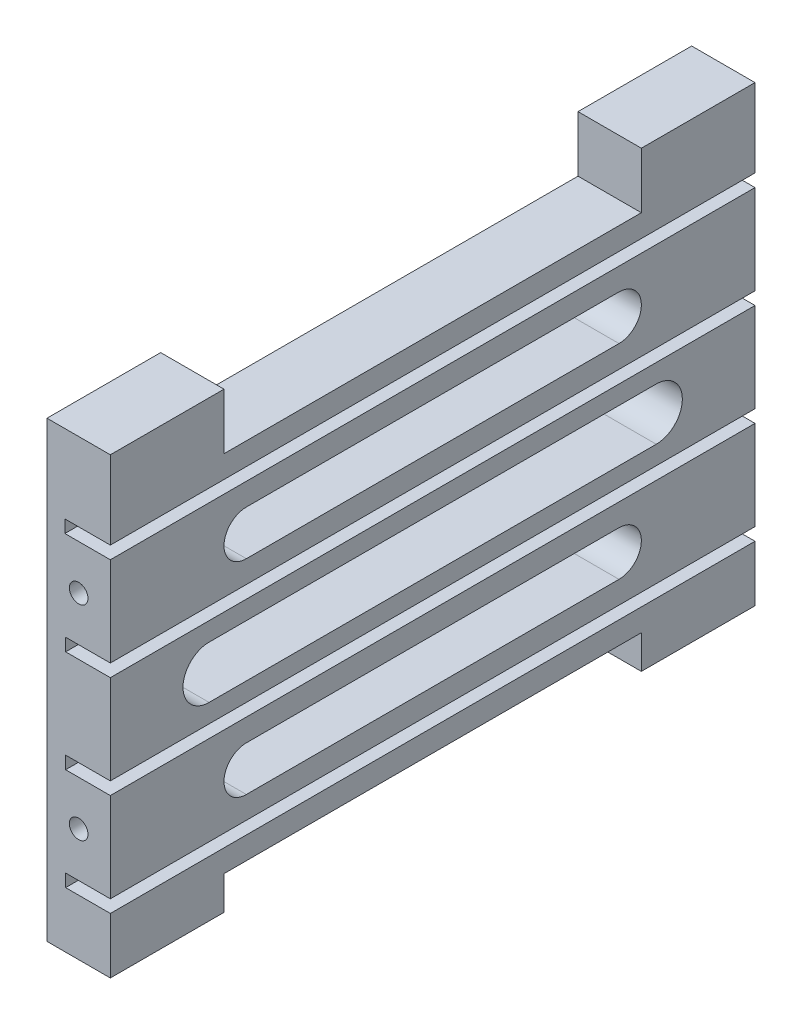
from build123d import *

# Parameters (mm, degrees)
BOSS_EXTRUDE1_DEPTH            = 86.5
M3X0_5_TAPPED_HOLE2_AT_2_COUNT = 2
M3X0_5_TAPPED_HOLE2_AT_2_PITCH = 27.4
M3X0_5_TAPPED_HOLE1_AT_2_COUNT = 2
M3X0_5_TAPPED_HOLE1_AT_2_PITCH = 49
SKETCH14_R                     = 3.5
CUT_EXTRUDE3_DEPTH             = 9.5
CUT_EXTRUDE1_DEPTH             = 9.5
SKETCH15_W                     = 56
SKETCH15_H                     = 7.5
CUT_EXTRUDE4_DEPTH             = 9.5
SKETCH16_W                     = 56
SKETCH16_H                     = 4.5
CUT_EXTRUDE5_DEPTH             = 9.5


with BuildPart() as part:
    # Sketch1 → Boss-Extrude1 (new body)
    with BuildSketch(Plane.XY):
        Polygon((0, 0), (0, 60.8), (8.5, 60.8), (8.5, 50.3), (2.4, 50.3), (2.4, 48.6), (8.5, 48.6), (8.5, 36.6), (2.5, 36.6), (2.5, 34.9), (8.5, 34.9), (8.5, 22.9), (2.5, 22.9), (2.5, 21.2), (8.5, 21.2), (8.5, 9.2), (2.5, 9.2), (2.5, 7.5), (8.5, 7.5), (8.5, 0), align=None)
    extrude(amount=BOSS_EXTRUDE1_DEPTH)

    # Sketch4 → M3x0.5 Tapped Hole2 (revolve, cut)
    with BuildSketch(Plane(origin=(4.25, 42.6, 86.5), x_dir=(0, -1, 0), z_dir=(1, 0, 0))):
        Polygon((0, 0), (0, 6.751075774), (1.25, 6), (1.25, 0), align=None)
    m3x0_5_tapped_hole2 = revolve(axis=Axis((4.25, 42.6, 92.85), (0, 0, -1)), mode=Mode.SUBTRACT)

    # M3x0.5 Tapped Hole2 at 2: M3x0.5 Tapped Hole2 ×2
    with Locations(*[(0, -i * M3X0_5_TAPPED_HOLE2_AT_2_PITCH, 0) for i in range(1, M3X0_5_TAPPED_HOLE2_AT_2_COUNT)]):
        add(m3x0_5_tapped_hole2, mode=Mode.SUBTRACT)

    # Mirror1: M3x0.5 Tapped Hole2 across plane
    add(m3x0_5_tapped_hole2.mirror(Plane.XY.offset(43.25)), mode=Mode.SUBTRACT)

    # Mirror1 copy 1 sketch → Mirror1 copy 1 (revolve, cut)
    with BuildSketch(Plane(origin=(4.25, 15.2, 0), x_dir=(0, -1, 0), z_dir=(1, 0, 0))):
        Polygon((0, 0), (0, -6.751075774), (1.25, -6), (1.25, 0), align=None)
    revolve(axis=Axis((4.25, 15.2, -6.35), (0, 0, -1)), mode=Mode.SUBTRACT)

    # Sketch11 → M3x0.5 Tapped Hole1 (revolve, cut)
    with BuildSketch(Plane(origin=(0, 5, 8.25), x_dir=(0, 0, 1), z_dir=(0, 1, 0))):
        Polygon((0, 0), (0, 4.751075774), (1.25, 4), (1.25, 0), align=None)
    m3x0_5_tapped_hole1 = revolve(axis=Axis((-6.35, 5, 8.25), (1, 0, 0)), mode=Mode.SUBTRACT)

    # M3x0.5 Tapped Hole1 at 2: M3x0.5 Tapped Hole1 ×2
    with Locations(*[(0, i * M3X0_5_TAPPED_HOLE1_AT_2_PITCH, 0) for i in range(1, M3X0_5_TAPPED_HOLE1_AT_2_COUNT)]):
        add(m3x0_5_tapped_hole1, mode=Mode.SUBTRACT)

    # Mirror2: M3x0.5 Tapped Hole1 across plane
    add(m3x0_5_tapped_hole1.mirror(Plane(origin=(0, 0, 43.25), x_dir=(1, 0, 0), z_dir=(0, 0, -1))), mode=Mode.SUBTRACT)

    # Mirror2 copy 1 sketch → Mirror2 copy 1 (revolve, cut)
    with BuildSketch(Plane(origin=(0, 54, 78.25), x_dir=(0, 0, -1), z_dir=(0, 1, 0))):
        Polygon((0, 0), (0, -4.751075774), (1.25, -4), (1.25, 0), align=None)
    revolve(axis=Axis((-6.35, 54, 78.25), (-1, 0, 0)), mode=Mode.SUBTRACT)

    # Sketch14 → Cut-Extrude3 (cut, through all)
    with BuildSketch(Plane(origin=(8.5, 0, 0), x_dir=(0, 0, -1), z_dir=(1, 0, 0))):
        with BuildLine():
            Line((-13.25, 32.4), (-73.25, 32.4))
            ThreePointArc((-73.25, 32.4), (-70.775126266, 31.374873734), (-69.75, 28.9))
            ThreePointArc((-69.75, 28.9), (-70.775126266, 26.425126266), (-73.25, 25.4))
            Line((-73.25, 25.4), (-13.25, 25.4))
            ThreePointArc((-13.25, 25.4), (-16.75, 28.9), (-13.25, 32.4))
        make_face()
        with Locations((-73.25, 28.9)):
            Circle(SKETCH14_R)
        with Locations((-13.25, 28.9)):
            Circle(SKETCH14_R)
    extrude(amount=-CUT_EXTRUDE3_DEPTH, mode=Mode.SUBTRACT)

    # Sketch12 → Cut-Extrude1 (cut, through all)
    with BuildSketch(Plane(origin=(8.5, 0, 0), x_dir=(0, 0, -1), z_dir=(1, 0, 0))):
        with BuildLine():
            Line((-18.25, 45.6), (-68.25, 45.6))
            ThreePointArc((-68.25, 45.6), (-71.25, 42.6), (-68.25, 39.6))
            Line((-68.25, 39.6), (-18.25, 39.6))
            ThreePointArc((-18.25, 39.6), (-15.25, 42.6), (-18.25, 45.6))
        make_face()
        with BuildLine():
            Line((-18.25, 18.2), (-68.25, 18.2))
            ThreePointArc((-68.25, 18.2), (-71.25, 15.2), (-68.25, 12.2))
            Line((-68.25, 12.2), (-18.25, 12.2))
            ThreePointArc((-18.25, 12.2), (-15.25, 15.2), (-18.25, 18.2))
        make_face()
    extrude(amount=-CUT_EXTRUDE1_DEPTH, mode=Mode.SUBTRACT)

    # Sketch15 → Cut-Extrude4 (cut, through all)
    with BuildSketch(Plane(origin=(8.5, 0, 0), x_dir=(0, 0, -1), z_dir=(1, 0, 0))):
        with Locations((-43.25, 57.05)):
            Rectangle(SKETCH15_W, SKETCH15_H)
    extrude(amount=-CUT_EXTRUDE4_DEPTH, mode=Mode.SUBTRACT)

    # Sketch16 → Cut-Extrude5 (cut, through all)
    with BuildSketch(Plane(origin=(8.5, 0, 0), x_dir=(0, 0, -1), z_dir=(1, 0, 0))):
        with Locations((-43.25, 2.25)):
            Rectangle(SKETCH16_W, SKETCH16_H)
    extrude(amount=-CUT_EXTRUDE5_DEPTH, mode=Mode.SUBTRACT)


solid = part.part
